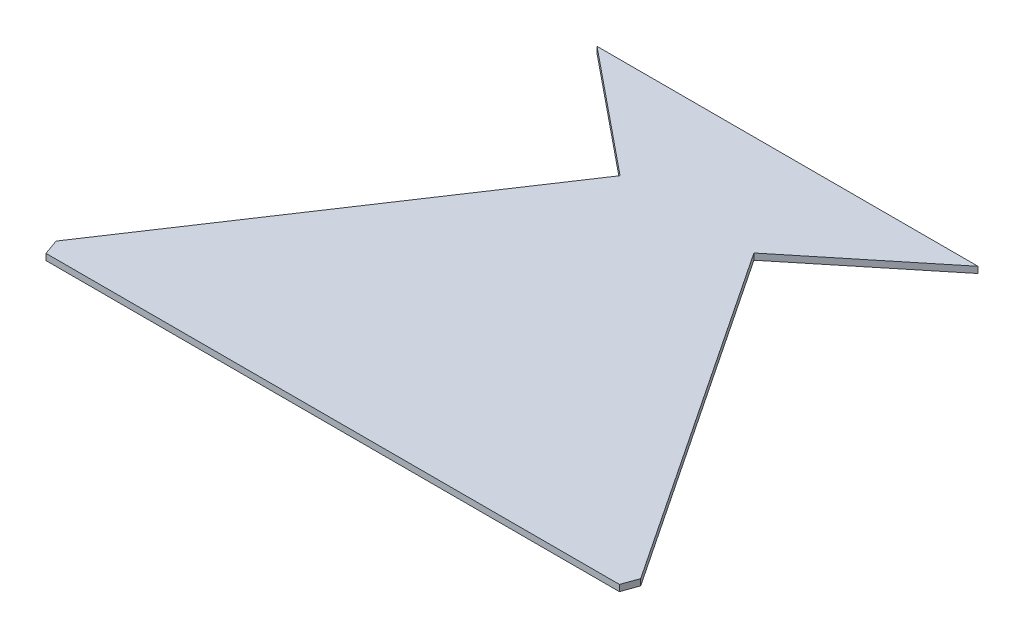
from build123d import *

# Parameters (mm, degrees)
BOSS_EXTRU_1_DEPTH = 2


with BuildPart() as part:
    # Esquisse1 → Boss.-Extru.1 (new body)
    with BuildSketch(Plane(origin=(0, 0, 0), x_dir=(1, 0, 0), z_dir=(0, 1, 0))):
        Polygon((0, 0), (182.415949505, 0), (184.200143461, 4.986368037), (112.495703751, 112.707662375), (151.804229589, 144.688132907), (30.611719916, 144.688132907), (69.920245754, 112.707662375), (-1.784193956, 4.986368037), align=None)
    extrude(amount=BOSS_EXTRU_1_DEPTH)


solid = part.part
